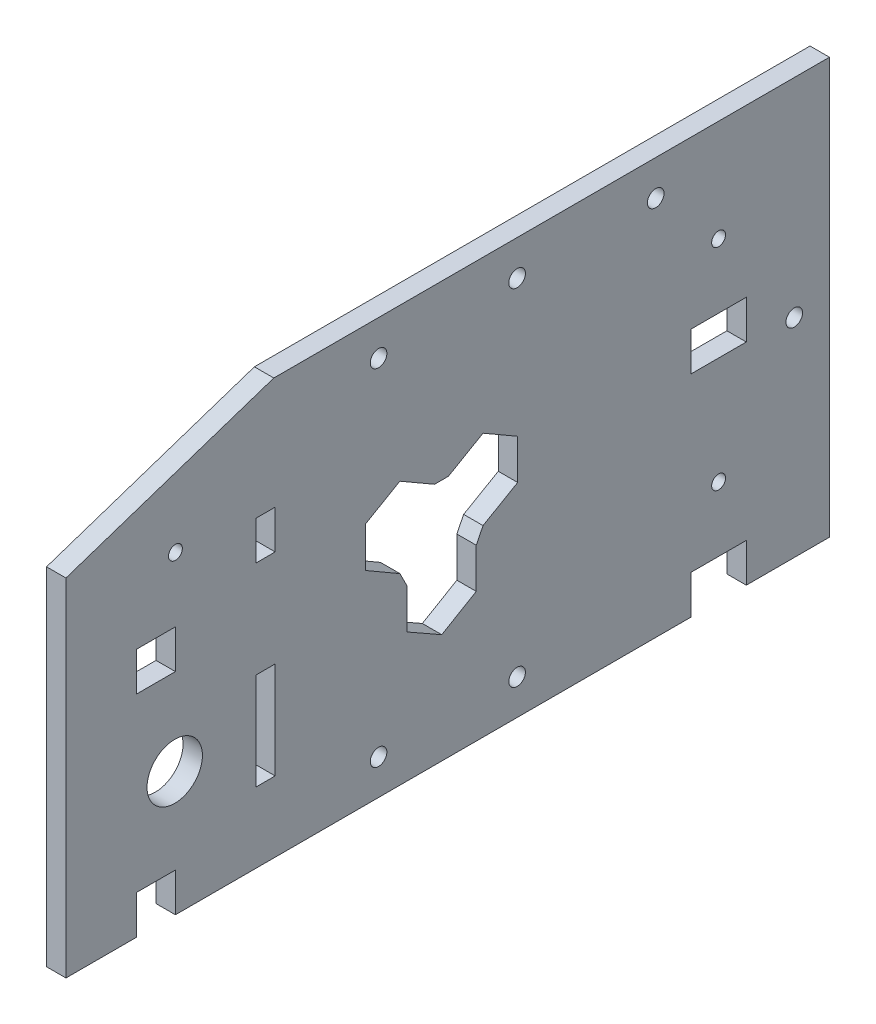
from build123d import *

# Parameters (mm, degrees)
SKETCH1_R                = 10
SKETCH1_R_2              = 2.5
SKETCH1_W                = 14
SKETCH1_H                = 14
SKETCH1_W_2              = 20
SKETCH1_W_3              = 7
SKETCH1_H_2              = 35
BOSS_EXTRUDE1_DEPTH      = 7
F_6_0_6_DIAMETER_HOLE1_D = 6


with BuildPart() as part:
    # Sketch1 → Boss-Extrude1 (new body)
    with BuildSketch(Plane(origin=(0, 0, 0), x_dir=(0, 0, -1), z_dir=(1, 0, 0))):
        Polygon((-118.5, -75), (67.5, -75), (67.5, -61), (87.5, -61), (87.5, -75), (117.5, -75), (117.5, 75), (-83, 75), (-158, 50), (-158, -75), (-132.5, -75), (-132.5, -61), (-118.5, -61), align=None)
        with Locations((-118.75, -30.05)):
            Circle(SKETCH1_R, mode=Mode.SUBTRACT)
        with Locations((77.5, 38.27)):
            Circle(SKETCH1_R_2, mode=Mode.SUBTRACT)
        with Locations((-118.5, 38.27)):
            Circle(SKETCH1_R_2, mode=Mode.SUBTRACT)
        with Locations((77.5, -37.73)):
            Circle(SKETCH1_R_2, mode=Mode.SUBTRACT)
        with Locations((-125.5, 8)):
            Rectangle(SKETCH1_W, SKETCH1_H, mode=Mode.SUBTRACT)
        with Locations((77.5, 8)):
            Rectangle(SKETCH1_W_2, SKETCH1_H, mode=Mode.SUBTRACT)
        Polygon((-22.397299346, -35.516686773), (-9.948649676, -28.211588915), (-9.948649676, -13.777832185), (-7.5, -8.867513459), (5, -1.650635095), (5, 12.783121635), (-7.5, 20), (-20, 12.783121635), (-25, 12.783121635), (-37.5, 20), (-50, 12.783121635), (-50, -1.650635095), (-37.5, -8.867513459), (-34.94864967, -13.955732953), (-34.94864967, -28.389489683), align=None, mode=Mode.SUBTRACT)
        with Locations((-86, 27.4)):
            Rectangle(SKETCH1_W_3, SKETCH1_H, mode=Mode.SUBTRACT)
        with Locations((-86, -32.1)):
            Rectangle(SKETCH1_W_3, SKETCH1_H_2, mode=Mode.SUBTRACT)
    extrude(amount=BOSS_EXTRUDE1_DEPTH)

    # Ø6.0 (6) Diameter Hole1 (through all)
    with Locations(Plane(origin=(7, -62.3, -4.8), x_dir=(0, 0, 1), z_dir=(1, 0, 0))):
        with Locations((0, 0), (-100, -62.3), (-50, -124.6), (0, -124.6), (50, -124.6), (50, 0)):
            Hole(F_6_0_6_DIAMETER_HOLE1_D / 2)


solid = part.part
